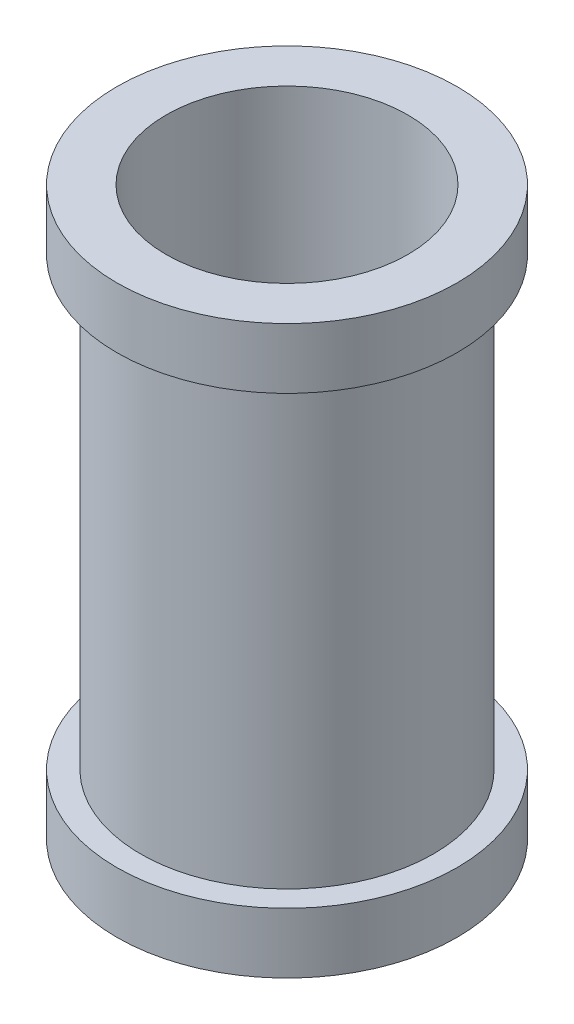
from build123d import *

# Parameters (mm, degrees)
SKETCH1_R               = 24.60625
SKETCH1_R_2             = 20.32
BOSS_EXTRUDE1_DEPTH     = 95.25
SKETCH2_R               = 28.575
SKETCH2_R_2             = 24.60625
BOSS_EXTRUDE2_DEPTH     = 95.25
SKETCH3_W               = 57.15
SKETCH3_H               = 74.93
CUT_EXTRUDE1_DEPTH      = 29.575
CUT_EXTRUDE1_DEPTH_BACK = 29.575
SKETCH4_R               = 24.60625
SKETCH4_R_2             = 20.32
BOSS_EXTRUDE3_DEPTH     = 74.93


with BuildPart() as part:
    # Sketch1 → Boss-Extrude1 (new body)
    with BuildSketch(Plane(origin=(0, 0, 0), x_dir=(1, 0, 0), z_dir=(0, 1, 0))):
        Circle(SKETCH1_R)
        Circle(SKETCH1_R_2, mode=Mode.SUBTRACT)
    extrude(amount=BOSS_EXTRUDE1_DEPTH)

    # Sketch2 → Boss-Extrude2 (add)
    with BuildSketch(Plane(origin=(0, 95.25, 0), x_dir=(1, 0, 0), z_dir=(0, 1, 0))):
        Circle(SKETCH2_R)
        Circle(SKETCH2_R_2, mode=Mode.SUBTRACT)
    extrude(amount=-BOSS_EXTRUDE2_DEPTH)

    # Sketch3 → Cut-Extrude1 (cut, two sides)
    with BuildSketch(Plane.XY) as cut_extrude1_sk:
        with Locations((0, 47.625)):
            Rectangle(SKETCH3_W, SKETCH3_H)
    extrude(amount=CUT_EXTRUDE1_DEPTH, mode=Mode.SUBTRACT)
    extrude(cut_extrude1_sk.sketch, amount=-CUT_EXTRUDE1_DEPTH_BACK, mode=Mode.SUBTRACT)

    # Sketch4 → Boss-Extrude3 (add)
    with BuildSketch(Plane(origin=(0, 10.16, 0), x_dir=(1, 0, 0), z_dir=(0, 1, 0))):
        Circle(SKETCH4_R)
        Circle(SKETCH4_R_2, mode=Mode.SUBTRACT)
    extrude(amount=BOSS_EXTRUDE3_DEPTH)


solid = part.part
